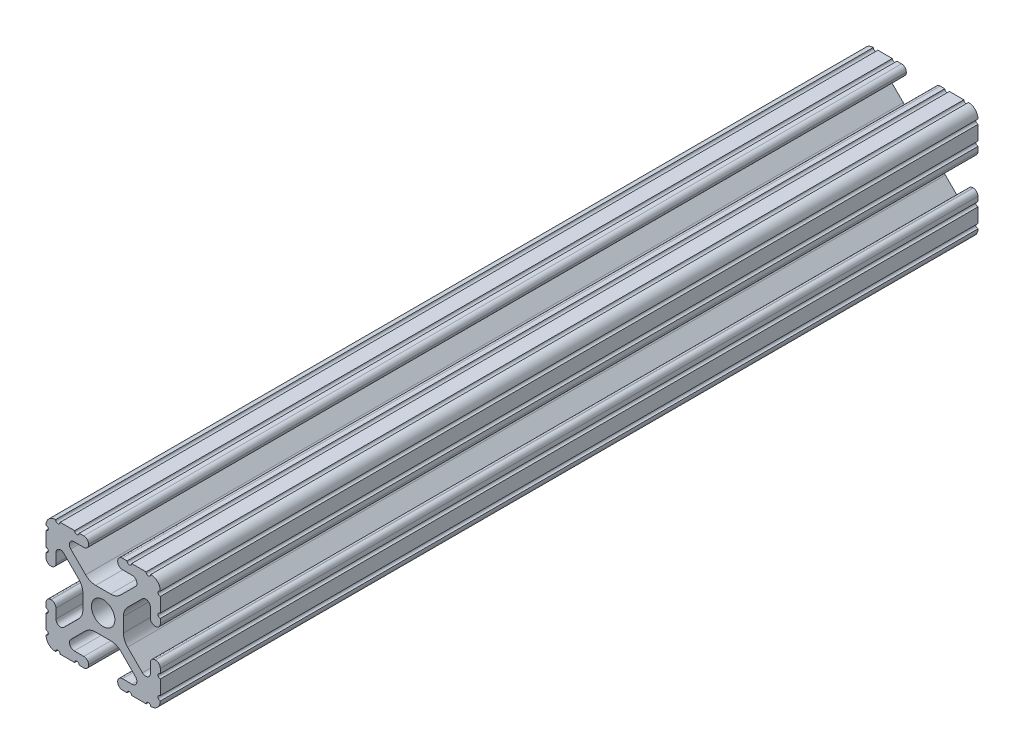
from build123d import *

# Parameters (mm, degrees)
SKETCH1_R           = 2.6035
BOSS_EXTRUDE1_DEPTH = 90.875


with BuildPart() as part:
    # Sketch1 → Boss-Extrude1 (new body, symmetric)
    with BuildSketch(Plane.XY):
        with BuildLine():
            Line((-7.179650497, -8.645192506), (-3.952270251, -5.423690499))
            ThreePointArc((-3.952270251, -5.423690499), (-2.922936451, -4.736929036), (-1.709253557, -4.4958))
            Line((-1.709253557, -4.4958), (1.709253557, -4.4958))
            ThreePointArc((1.709253557, -4.4958), (2.922936451, -4.736929036), (3.952270251, -5.423690499))
            Line((3.952270251, -5.423690499), (7.179650497, -8.645192506))
            ThreePointArc((7.179650497, -8.645192506), (7.41473083, -9.822813117), (6.416408329, -10.4902))
            Line((6.416408329, -10.4902), (4.287512407, -10.4902))
            ThreePointArc((4.287512407, -10.4902), (3.54574862, -10.79744862), (3.2385, -11.539212407))
            Line((3.2385, -11.539212407), (3.2385, -11.650987593))
            ThreePointArc((3.2385, -11.650987593), (3.54574862, -12.39275138), (4.287512407, -12.7))
            Line((4.287512407, -12.7), (5.317126718, -12.7))
            ThreePointArc((5.317126718, -12.7), (5.825126718, -12.192), (6.333126718, -12.7))
            Line((6.333126718, -12.7), (9.550443118, -12.7))
            ThreePointArc((9.550443118, -12.7), (10.058366869, -12.192000006), (10.566443095, -12.699847501))
            ThreePointArc((10.566443095, -12.699847501), (12.082537762, -12.08250727), (12.699846982, -10.566399977))
            ThreePointArc((12.699846982, -10.566399977), (12.192000006, -10.058323491), (12.7, -9.5504))
            Line((12.7, -9.5504), (12.7, -6.3330836))
            ThreePointArc((12.7, -6.3330836), (12.192, -5.8250836), (12.7, -5.3170836))
            Line((12.7, -5.3170836), (12.7, -4.287469289))
            ThreePointArc((12.7, -4.287469289), (12.39275138, -3.545705502), (11.650987593, -3.238456882))
            Line((11.650987593, -3.238456882), (11.539212407, -3.238456882))
            ThreePointArc((11.539212407, -3.238456882), (10.79744862, -3.545705502), (10.4902, -4.287469289))
            Line((10.4902, -4.287469289), (10.4902, -6.402089023))
            ThreePointArc((10.4902, -6.402089023), (9.856505071, -7.351067942), (8.737131347, -7.129408934))
            Line((8.737131347, -7.129408934), (5.441005833, -3.840816462))
            ThreePointArc((5.441005833, -3.840816462), (4.750877967, -2.809883091), (4.5085, -1.593185507))
            Line((4.5085, -1.593185507), (4.5085, 1.593185507))
            ThreePointArc((4.5085, 1.593185507), (4.750877967, 2.809883091), (5.441005833, 3.840816462))
            Line((5.441005833, 3.840816462), (8.737131347, 7.129408934))
            ThreePointArc((8.737131347, 7.129408934), (9.856505071, 7.351067942), (10.4902, 6.402089023))
            Line((10.4902, 6.402089023), (10.4902, 4.287469289))
            ThreePointArc((10.4902, 4.287469289), (10.79744862, 3.545705502), (11.539212407, 3.238456882))
            Line((11.539212407, 3.238456882), (11.650987593, 3.238456882))
            ThreePointArc((11.650987593, 3.238456882), (12.39275138, 3.545705502), (12.7, 4.287469289))
            Line((12.7, 4.287469289), (12.7, 5.3170836))
            ThreePointArc((12.7, 5.3170836), (12.192, 5.8250836), (12.7, 6.3330836))
            Line((12.7, 6.3330836), (12.7, 9.5504))
            ThreePointArc((12.7, 9.5504), (12.192000006, 10.058323491), (12.699846982, 10.566399977))
            ThreePointArc((12.699846982, 10.566399977), (12.082537762, 12.08250727), (10.566443095, 12.699847501))
            ThreePointArc((10.566443095, 12.699847501), (10.058366869, 12.192000006), (9.550443118, 12.7))
            Line((9.550443118, 12.7), (6.333126718, 12.7))
            ThreePointArc((6.333126718, 12.7), (5.825126718, 12.192), (5.317126718, 12.7))
            Line((5.317126718, 12.7), (4.287512407, 12.7))
            ThreePointArc((4.287512407, 12.7), (3.54574862, 12.39275138), (3.2385, 11.650987593))
            Line((3.2385, 11.650987593), (3.2385, 11.539212407))
            ThreePointArc((3.2385, 11.539212407), (3.54574862, 10.79744862), (4.287512407, 10.4902))
            Line((4.287512407, 10.4902), (6.476788598, 10.4902))
            ThreePointArc((6.476788598, 10.4902), (7.432222385, 9.85140422), (7.207036008, 8.724370562))
            Line((7.207036008, 8.724370562), (3.898272566, 5.423169045))
            ThreePointArc((3.898272566, 5.423169045), (2.869120213, 4.736787962), (1.655778399, 4.4958))
            Line((1.655778399, 4.4958), (-1.655778399, 4.4958))
            ThreePointArc((-1.655778399, 4.4958), (-2.869120213, 4.736787962), (-3.898272566, 5.423169045))
            Line((-3.898272566, 5.423169045), (-7.207036008, 8.724370562))
            ThreePointArc((-7.207036008, 8.724370562), (-7.432222385, 9.85140422), (-6.476788598, 10.4902))
            Line((-6.476788598, 10.4902), (-4.287512407, 10.4902))
            ThreePointArc((-4.287512407, 10.4902), (-3.54574862, 10.79744862), (-3.2385, 11.539212407))
            Line((-3.2385, 11.539212407), (-3.2385, 11.650987593))
            ThreePointArc((-3.2385, 11.650987593), (-3.54574862, 12.39275138), (-4.287512407, 12.7))
            Line((-4.287512407, 12.7), (-5.317126718, 12.7))
            ThreePointArc((-5.317126718, 12.7), (-5.825126718, 12.192), (-6.333126718, 12.7))
            Line((-6.333126718, 12.7), (-9.550443118, 12.7))
            ThreePointArc((-9.550443118, 12.7), (-10.058366869, 12.192000006), (-10.566443095, 12.699847501))
            ThreePointArc((-10.566443095, 12.699847501), (-12.082537762, 12.08250727), (-12.699846982, 10.566399977))
            ThreePointArc((-12.699846982, 10.566399977), (-12.192000006, 10.058323491), (-12.7, 9.5504))
            Line((-12.7, 9.5504), (-12.7, 6.3330836))
            ThreePointArc((-12.7, 6.3330836), (-12.192, 5.8250836), (-12.7, 5.3170836))
            Line((-12.7, 5.3170836), (-12.7, 4.287469289))
            ThreePointArc((-12.7, 4.287469289), (-12.39275138, 3.545705502), (-11.650987593, 3.238456882))
            Line((-11.650987593, 3.238456882), (-11.539212407, 3.238456882))
            ThreePointArc((-11.539212407, 3.238456882), (-10.79744862, 3.545705502), (-10.4902, 4.287469289))
            Line((-10.4902, 4.287469289), (-10.4902, 6.402089023))
            ThreePointArc((-10.4902, 6.402089023), (-9.856505071, 7.351067942), (-8.737131347, 7.129408934))
            Line((-8.737131347, 7.129408934), (-5.441005833, 3.840816462))
            ThreePointArc((-5.441005833, 3.840816462), (-4.750877967, 2.809883091), (-4.5085, 1.593185507))
            Line((-4.5085, 1.593185507), (-4.5085, -1.593185507))
            ThreePointArc((-4.5085, -1.593185507), (-4.750877967, -2.809883091), (-5.441005833, -3.840816462))
            Line((-5.441005833, -3.840816462), (-8.737131347, -7.129408934))
            ThreePointArc((-8.737131347, -7.129408934), (-9.856505071, -7.351067942), (-10.4902, -6.402089023))
            Line((-10.4902, -6.402089023), (-10.4902, -4.287469289))
            ThreePointArc((-10.4902, -4.287469289), (-10.79744862, -3.545705502), (-11.539212407, -3.238456882))
            Line((-11.539212407, -3.238456882), (-11.650987593, -3.238456882))
            ThreePointArc((-11.650987593, -3.238456882), (-12.39275138, -3.545705502), (-12.7, -4.287469289))
            Line((-12.7, -4.287469289), (-12.7, -5.3170836))
            ThreePointArc((-12.7, -5.3170836), (-12.192, -5.8250836), (-12.7, -6.3330836))
            Line((-12.7, -6.3330836), (-12.7, -9.5504))
            ThreePointArc((-12.7, -9.5504), (-12.192000006, -10.058323491), (-12.699846982, -10.566399977))
            ThreePointArc((-12.699846982, -10.566399977), (-12.082537762, -12.08250727), (-10.566443095, -12.699847501))
            ThreePointArc((-10.566443095, -12.699847501), (-10.058366869, -12.192000006), (-9.550443118, -12.7))
            Line((-9.550443118, -12.7), (-6.333126718, -12.7))
            ThreePointArc((-6.333126718, -12.7), (-5.825126718, -12.192), (-5.317126718, -12.7))
            Line((-5.317126718, -12.7), (-4.287512407, -12.7))
            ThreePointArc((-4.287512407, -12.7), (-3.54574862, -12.39275138), (-3.2385, -11.650987593))
            Line((-3.2385, -11.650987593), (-3.2385, -11.539212407))
            ThreePointArc((-3.2385, -11.539212407), (-3.54574862, -10.79744862), (-4.287512407, -10.4902))
            Line((-4.287512407, -10.4902), (-6.416408329, -10.4902))
            ThreePointArc((-6.416408329, -10.4902), (-7.41473083, -9.822813117), (-7.179650497, -8.645192506))
        make_face()
        Circle(SKETCH1_R, mode=Mode.SUBTRACT)
    extrude(amount=BOSS_EXTRUDE1_DEPTH, both=True)


solid = part.part
